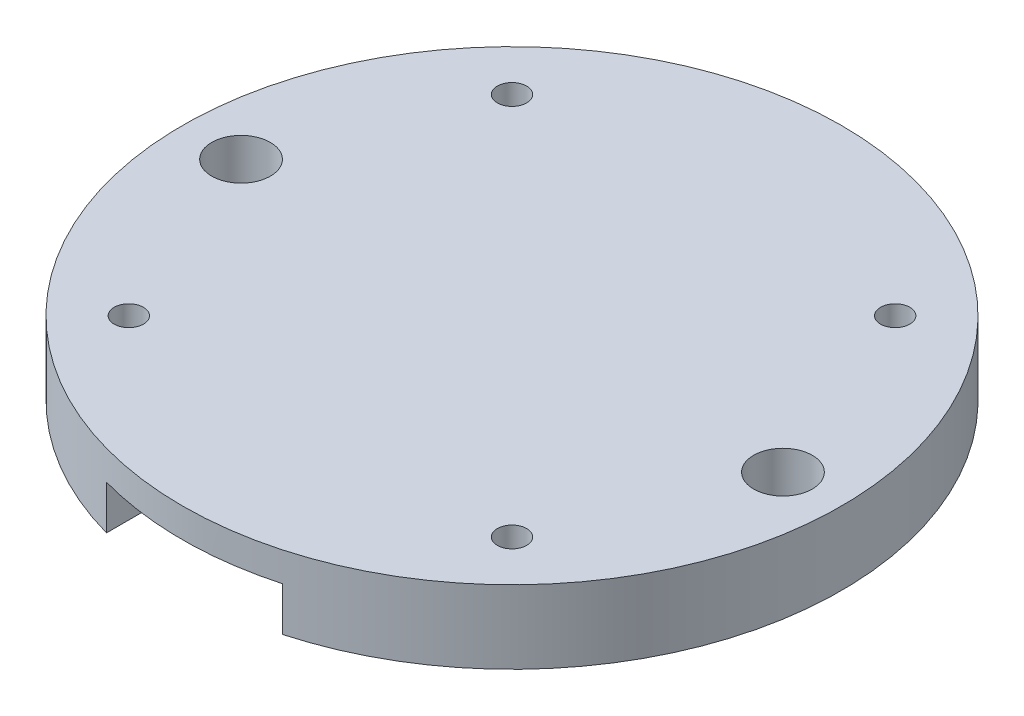
from build123d import *

# Parameters (mm, degrees)
SKETCH_1_R               = 22.5
SKETCH_1_R_2             = 2
EXTRUDE_1_DEPTH          = 5
SKETCH_2_R               = 10.25
CUT_EXTRUDE_1_DEPTH      = 1
SKETCH_3_W               = 12
SKETCH_3_H               = 3
CUT_EXTRUDE_2_DEPTH      = 23.5
CUT_EXTRUDE_2_DEPTH_BACK = 23.5
SKETCH_4_R               = 1
CUT_EXTRUDE_3_DEPTH      = 6


with BuildPart() as part:
    # 草图1 → 凸台-拉伸1 (new body)
    with BuildSketch(Plane(origin=(0, 0, 0), x_dir=(1, 0, 0), z_dir=(0, 1, 0))):
        with Locations(Location((0, 0, 0), (0, 0, 270))):  # turned: the seam where the file's is
            Circle(SKETCH_1_R)
        with Locations(Location((18.5, 0, 0), (0, 0, 270))):  # turned: the seam where the file's is
            Circle(SKETCH_1_R_2, mode=Mode.SUBTRACT)
        with Locations(Location((-18.5, 0, 0), (0, 0, 90))):  # turned: the seam where the file's is
            Circle(SKETCH_1_R_2, mode=Mode.SUBTRACT)
    extrude(amount=EXTRUDE_1_DEPTH)

    # 草图2 → 切除-拉伸1 (cut)
    with BuildSketch(Plane(origin=(0, 0, 0), x_dir=(1, 0, 0), z_dir=(0, 1, 0))):
        with Locations(Location((0, 0, 0), (0, 0, 270))):  # turned: the seam where the file's is
            Circle(SKETCH_2_R)
    extrude(amount=CUT_EXTRUDE_1_DEPTH, mode=Mode.SUBTRACT)

    # 草图3 → 切除-拉伸2 (cut, two sides)
    with BuildSketch(Plane.XY) as cut_extrude_2_sk:
        with Locations((0, 1.5)):
            Rectangle(SKETCH_3_W, SKETCH_3_H)
    extrude(amount=CUT_EXTRUDE_2_DEPTH, mode=Mode.SUBTRACT)
    extrude(cut_extrude_2_sk.sketch, amount=-CUT_EXTRUDE_2_DEPTH_BACK, mode=Mode.SUBTRACT)

    # 草图4 → 切除-拉伸3 (cut, through all)
    with BuildSketch(Plane(origin=(0, 5, 0), x_dir=(1, 0, 0), z_dir=(0, 1, 0))):
        with Locations(Location((13.081475452, 13.081475452, 0), (0, 0, 270))):  # turned: the seam where the file's is
            Circle(SKETCH_4_R)
        with Locations(Location((13.081475452, -13.081475452, 0), (0, 0, 90))):  # turned: the seam where the file's is
            Circle(SKETCH_4_R)
        with Locations(Location((-13.081475452, 13.081475452, 0), (0, 0, 90))):  # turned: the seam where the file's is
            Circle(SKETCH_4_R)
        with Locations(Location((-13.081475452, -13.081475452, 0), (0, 0, 270))):  # turned: the seam where the file's is
            Circle(SKETCH_4_R)
    extrude(amount=-CUT_EXTRUDE_3_DEPTH, mode=Mode.SUBTRACT)


solid = part.part
